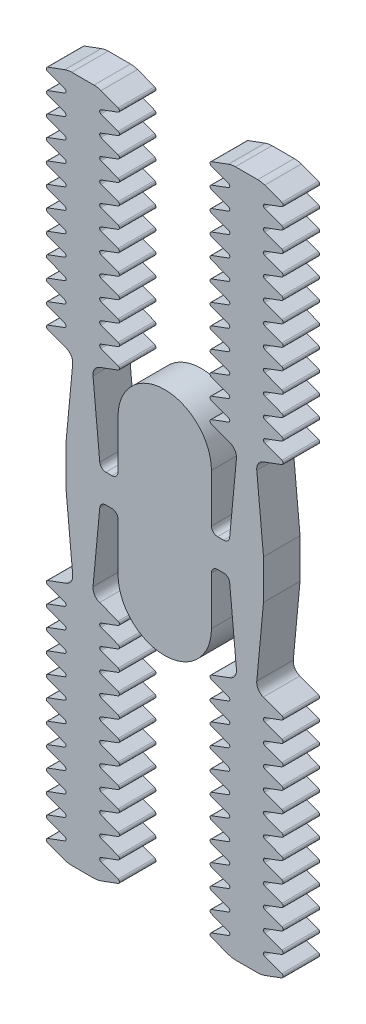
from build123d import *

# Parameters (mm, degrees)
BOSS_EXTRUDE1_DEPTH = 18


with BuildPart() as part:
    # Sketch1 → Boss-Extrude1 (new body)
    with BuildSketch(Plane.XY):
        with BuildLine():
            Line((23, 33.741347448), (23, 10))
            ThreePointArc((23, 10), (23.878679656, 7.878679656), (26, 7))
            Line((26, 7), (29.013205013, 7))
            ThreePointArc((29.013205013, 7), (31.032672098, 7.781497646), (32, 9.718831538))
            Line((32, 9.718831538), (35.321269761, 45))
            ThreePointArc((35.321269761, 45), (34.577858607, 48.127246847), (32.084323625, 50.155698542))
            Line((32.084323625, 50.155698542), (22.973060659, 53.540131589))
            ThreePointArc((22.973060659, 53.540131589), (22.321269761, 54.477548477), (22.973060659, 55.414965365))
            Line((22.973060659, 55.414965365), (31.386349055, 58.540131589))
            ThreePointArc((31.386349055, 58.540131589), (32.038139954, 59.477548477), (31.386349055, 60.414965365))
            Line((31.386349055, 60.414965365), (22.973060659, 63.540131589))
            ThreePointArc((22.973060659, 63.540131589), (22.321269761, 64.477548477), (22.973060659, 65.414965365))
            Line((22.973060659, 65.414965365), (31.386349055, 68.540131589))
            ThreePointArc((31.386349055, 68.540131589), (32.038140307, 69.47754842), (31.386349409, 70.414965496))
            Line((31.386349409, 70.414965496), (22.973061013, 73.540131721))
            ThreePointArc((22.973061013, 73.540131721), (22.321270115, 74.477548608), (22.973061013, 75.414965496))
            Line((22.973061013, 75.414965496), (31.386349763, 78.540131852))
            ThreePointArc((31.386349763, 78.540131852), (32.038140661, 79.47754874), (31.386349763, 80.414965627))
            Line((31.386349763, 80.414965627), (22.973061367, 83.540131852))
            ThreePointArc((22.973061367, 83.540131852), (22.321270469, 84.47754874), (22.973061367, 85.414965627))
            Line((22.973061367, 85.414965627), (31.386350116, 88.540131983))
            ThreePointArc((31.386350116, 88.540131983), (32.038141014, 89.477548871), (31.386350116, 90.414965759))
            Line((31.386350116, 90.414965759), (22.97306172, 93.540131983))
            ThreePointArc((22.97306172, 93.540131983), (22.321270822, 94.477548871), (22.97306172, 95.414965759))
            Line((22.97306172, 95.414965759), (31.38635047, 98.540132115))
            ThreePointArc((31.38635047, 98.540132115), (32.038141368, 99.477549002), (31.38635047, 100.41496589))
            Line((31.38635047, 100.41496589), (22.973062074, 103.540132115))
            ThreePointArc((22.973062074, 103.540132115), (22.321271176, 104.477549002), (22.973062074, 105.41496589))
            Line((22.973062074, 105.41496589), (31.386350823, 108.540132246))
            ThreePointArc((31.386350823, 108.540132246), (32.038141722, 109.477549134), (31.386350823, 110.414966021))
            Line((31.386350823, 110.414966021), (22.973062428, 113.540132246))
            ThreePointArc((22.973062428, 113.540132246), (22.321271529, 114.477549134), (22.973062428, 115.414966021))
            Line((22.973062428, 115.414966021), (31.386351177, 118.540132377))
            ThreePointArc((31.386351177, 118.540132377), (32.038142075, 119.477549265), (31.386351177, 120.414966153))
            Line((31.386351177, 120.414966153), (22.973062781, 123.540132377))
            ThreePointArc((22.973062781, 123.540132377), (22.321271883, 124.477549265), (22.973062781, 125.414966153))
            Line((22.973062781, 125.414966153), (31.386351531, 128.540132509))
            ThreePointArc((31.386351531, 128.540132509), (32.038142429, 129.477549396), (31.386351531, 130.414966284))
            Line((31.386351531, 130.414966284), (22.973063135, 133.540132509))
            ThreePointArc((22.973063135, 133.540132509), (22.321272237, 134.477549396), (22.973063135, 135.414966284))
            Line((22.973063135, 135.414966284), (31.386351884, 138.54013264))
            ThreePointArc((31.386351884, 138.54013264), (32.038142782, 139.477549528), (31.386351884, 140.414966415))
            Line((31.386351884, 140.414966415), (22.973063488, 143.54013264))
            ThreePointArc((22.973063488, 143.54013264), (22.32127259, 144.477549528), (22.973063488, 145.414966415))
            Line((22.973063488, 145.414966415), (31.386352238, 148.540132771))
            ThreePointArc((31.386352238, 148.540132771), (32.038143136, 149.477549659), (31.386352238, 150.414966547))
            Line((31.386352238, 150.414966547), (22.973063842, 153.540132771))
            ThreePointArc((22.973063842, 153.540132771), (22.321272944, 154.477549659), (22.973063842, 155.414966547))
            Line((22.973063842, 155.414966547), (31.386352591, 158.540132903))
            ThreePointArc((31.386352591, 158.540132903), (32.03814349, 159.47754979), (31.386352591, 160.414966678))
            Line((31.386352591, 160.414966678), (22.973064196, 163.540132903))
            ThreePointArc((22.973064196, 163.540132903), (22.321273297, 164.47754979), (22.973064196, 165.414966678))
            Line((22.973064196, 165.414966678), (31.386352591, 168.540132903))
            ThreePointArc((31.386352591, 168.540132903), (33.082959494, 169.005275306), (34.834824138, 169.165907512))
            Line((34.834824138, 169.165907512), (45.807715385, 169.165907512))
            ThreePointArc((45.807715385, 169.165907512), (47.559580029, 169.005275306), (49.256186931, 168.540132903))
            Line((49.256186931, 168.540132903), (57.669475327, 165.414966678))
            ThreePointArc((57.669475327, 165.414966678), (58.321266225, 164.47754979), (57.669475327, 163.540132903))
            Line((57.669475327, 163.540132903), (49.256186931, 160.414966678))
            ThreePointArc((49.256186931, 160.414966678), (48.604396033, 159.47754979), (49.256186931, 158.540132903))
            Line((49.256186931, 158.540132903), (57.669475681, 155.414966547))
            ThreePointArc((57.669475681, 155.414966547), (58.321266579, 154.477549659), (57.669475681, 153.540132771))
            Line((57.669475681, 153.540132771), (49.256187285, 150.414966547))
            ThreePointArc((49.256187285, 150.414966547), (48.604396387, 149.477549659), (49.256187285, 148.540132771))
            Line((49.256187285, 148.540132771), (57.669476034, 145.414966415))
            ThreePointArc((57.669476034, 145.414966415), (58.321266932, 144.477549528), (57.669476034, 143.54013264))
            Line((57.669476034, 143.54013264), (49.256187638, 140.414966415))
            ThreePointArc((49.256187638, 140.414966415), (48.60439674, 139.477549528), (49.256187638, 138.54013264))
            Line((49.256187638, 138.54013264), (57.669476388, 135.414966284))
            ThreePointArc((57.669476388, 135.414966284), (58.321267286, 134.477549396), (57.669476388, 133.540132509))
            Line((57.669476388, 133.540132509), (49.256187992, 130.414966284))
            ThreePointArc((49.256187992, 130.414966284), (48.604397094, 129.477549396), (49.256187992, 128.540132509))
            Line((49.256187992, 128.540132509), (57.669476742, 125.414966153))
            ThreePointArc((57.669476742, 125.414966153), (58.32126764, 124.477549265), (57.669476742, 123.540132377))
            Line((57.669476742, 123.540132377), (49.256188346, 120.414966153))
            ThreePointArc((49.256188346, 120.414966153), (48.604397448, 119.477549265), (49.256188346, 118.540132377))
            Line((49.256188346, 118.540132377), (57.669477095, 115.414966021))
            ThreePointArc((57.669477095, 115.414966021), (58.321267993, 114.477549134), (57.669477095, 113.540132246))
            Line((57.669477095, 113.540132246), (49.256188699, 110.414966021))
            ThreePointArc((49.256188699, 110.414966021), (48.604397801, 109.477549134), (49.256188699, 108.540132246))
            Line((49.256188699, 108.540132246), (57.669477449, 105.41496589))
            ThreePointArc((57.669477449, 105.41496589), (58.321268347, 104.477549002), (57.669477449, 103.540132115))
            Line((57.669477449, 103.540132115), (49.256189053, 100.41496589))
            ThreePointArc((49.256189053, 100.41496589), (48.604398155, 99.477549002), (49.256189053, 98.540132115))
            Line((49.256189053, 98.540132115), (57.669477802, 95.414965759))
            ThreePointArc((57.669477802, 95.414965759), (58.321268701, 94.477548871), (57.669477802, 93.540131983))
            Line((57.669477802, 93.540131983), (49.256189406, 90.414965759))
            ThreePointArc((49.256189406, 90.414965759), (48.604398508, 89.477548871), (49.256189406, 88.540131983))
            Line((49.256189406, 88.540131983), (57.669478156, 85.414965627))
            ThreePointArc((57.669478156, 85.414965627), (58.321269054, 84.47754874), (57.669478156, 83.540131852))
            Line((57.669478156, 83.540131852), (49.25618976, 80.414965627))
            ThreePointArc((49.25618976, 80.414965627), (48.604398862, 79.47754874), (49.25618976, 78.540131852))
            Line((49.25618976, 78.540131852), (57.66947851, 75.414965496))
            ThreePointArc((57.66947851, 75.414965496), (58.321269408, 74.477548608), (57.66947851, 73.540131721))
            Line((57.66947851, 73.540131721), (49.256190114, 70.414965496))
            ThreePointArc((49.256190114, 70.414965496), (48.604399216, 69.47754842), (49.256190467, 68.540131589))
            Line((49.256190467, 68.540131589), (57.669478863, 65.414965365))
            ThreePointArc((57.669478863, 65.414965365), (58.321269761, 64.477548477), (57.669478863, 63.540131589))
            Line((57.669478863, 63.540131589), (49.256190467, 60.414965365))
            ThreePointArc((49.256190467, 60.414965365), (48.604399569, 59.477548477), (49.256190467, 58.540131589))
            Line((49.256190467, 58.540131589), (57.669478863, 55.414965365))
            ThreePointArc((57.669478863, 55.414965365), (58.321269761, 54.477548477), (57.669478863, 53.540131589))
            Line((57.669478863, 53.540131589), (48.558215898, 50.155698542))
            ThreePointArc((48.558215898, 50.155698542), (46.064680916, 48.127246847), (45.321269761, 45))
            Line((45.321269761, 45), (48.642539523, 9.718831538))
            Line((48.642539523, 9.718831538), (48.642539523, -9.718831538))
            Line((48.642539523, -9.718831538), (45.321269761, -45))
            ThreePointArc((45.321269761, -45), (46.064680916, -48.127246847), (48.558215898, -50.155698542))
            Line((48.558215898, -50.155698542), (57.669478863, -53.540131589))
            ThreePointArc((57.669478863, -53.540131589), (58.321269761, -54.477548477), (57.669478863, -55.414965365))
            Line((57.669478863, -55.414965365), (49.256190467, -58.540131589))
            ThreePointArc((49.256190467, -58.540131589), (48.604399569, -59.477548477), (49.256190467, -60.414965365))
            Line((49.256190467, -60.414965365), (57.669478863, -63.540131589))
            ThreePointArc((57.669478863, -63.540131589), (58.321269761, -64.477548477), (57.669478863, -65.414965365))
            Line((57.669478863, -65.414965365), (49.256190467, -68.540131589))
            ThreePointArc((49.256190467, -68.540131589), (48.604399216, -69.47754842), (49.256190114, -70.414965496))
            Line((49.256190114, -70.414965496), (57.66947851, -73.540131721))
            ThreePointArc((57.66947851, -73.540131721), (58.321269408, -74.477548608), (57.66947851, -75.414965496))
            Line((57.66947851, -75.414965496), (49.25618976, -78.540131852))
            ThreePointArc((49.25618976, -78.540131852), (48.604398862, -79.47754874), (49.25618976, -80.414965627))
            Line((49.25618976, -80.414965627), (57.669478156, -83.540131852))
            ThreePointArc((57.669478156, -83.540131852), (58.321269054, -84.47754874), (57.669478156, -85.414965627))
            Line((57.669478156, -85.414965627), (49.256189406, -88.540131983))
            ThreePointArc((49.256189406, -88.540131983), (48.604398508, -89.477548871), (49.256189406, -90.414965759))
            Line((49.256189406, -90.414965759), (57.669477802, -93.540131983))
            ThreePointArc((57.669477802, -93.540131983), (58.321268701, -94.477548871), (57.669477802, -95.414965759))
            Line((57.669477802, -95.414965759), (49.256189053, -98.540132115))
            ThreePointArc((49.256189053, -98.540132115), (48.604398155, -99.477549002), (49.256189053, -100.41496589))
            Line((49.256189053, -100.41496589), (57.669477449, -103.540132115))
            ThreePointArc((57.669477449, -103.540132115), (58.321268347, -104.477549002), (57.669477449, -105.41496589))
            Line((57.669477449, -105.41496589), (49.256188699, -108.540132246))
            ThreePointArc((49.256188699, -108.540132246), (48.604397801, -109.477549134), (49.256188699, -110.414966021))
            Line((49.256188699, -110.414966021), (57.669477095, -113.540132246))
            ThreePointArc((57.669477095, -113.540132246), (58.321267993, -114.477549134), (57.669477095, -115.414966021))
            Line((57.669477095, -115.414966021), (49.256188346, -118.540132377))
            ThreePointArc((49.256188346, -118.540132377), (48.604397448, -119.477549265), (49.256188346, -120.414966153))
            Line((49.256188346, -120.414966153), (57.669476742, -123.540132377))
            ThreePointArc((57.669476742, -123.540132377), (58.32126764, -124.477549265), (57.669476742, -125.414966153))
            Line((57.669476742, -125.414966153), (49.256187992, -128.540132509))
            ThreePointArc((49.256187992, -128.540132509), (48.604397094, -129.477549396), (49.256187992, -130.414966284))
            Line((49.256187992, -130.414966284), (57.669476388, -133.540132509))
            ThreePointArc((57.669476388, -133.540132509), (58.321267286, -134.477549396), (57.669476388, -135.414966284))
            Line((57.669476388, -135.414966284), (49.256187638, -138.54013264))
            ThreePointArc((49.256187638, -138.54013264), (48.60439674, -139.477549528), (49.256187638, -140.414966415))
            Line((49.256187638, -140.414966415), (57.669476034, -143.54013264))
            ThreePointArc((57.669476034, -143.54013264), (58.321266932, -144.477549528), (57.669476034, -145.414966415))
            Line((57.669476034, -145.414966415), (49.256187285, -148.540132771))
            ThreePointArc((49.256187285, -148.540132771), (48.604396387, -149.477549659), (49.256187285, -150.414966547))
            Line((49.256187285, -150.414966547), (57.669475681, -153.540132771))
            ThreePointArc((57.669475681, -153.540132771), (58.321266579, -154.477549659), (57.669475681, -155.414966547))
            Line((57.669475681, -155.414966547), (49.256186931, -158.540132903))
            ThreePointArc((49.256186931, -158.540132903), (48.604396033, -159.47754979), (49.256186931, -160.414966678))
            Line((49.256186931, -160.414966678), (57.669475327, -163.540132903))
            ThreePointArc((57.669475327, -163.540132903), (58.321266225, -164.47754979), (57.669475327, -165.414966678))
            Line((57.669475327, -165.414966678), (49.256186931, -168.540132903))
            ThreePointArc((49.256186931, -168.540132903), (47.559580029, -169.005275306), (45.807715385, -169.165907512))
            Line((45.807715385, -169.165907512), (34.834824138, -169.165907512))
            ThreePointArc((34.834824138, -169.165907512), (33.082959494, -169.005275306), (31.386352591, -168.540132903))
            Line((31.386352591, -168.540132903), (22.973064196, -165.414966678))
            ThreePointArc((22.973064196, -165.414966678), (22.321273297, -164.47754979), (22.973064196, -163.540132903))
            Line((22.973064196, -163.540132903), (31.386352591, -160.414966678))
            ThreePointArc((31.386352591, -160.414966678), (32.03814349, -159.47754979), (31.386352591, -158.540132903))
            Line((31.386352591, -158.540132903), (22.973063842, -155.414966547))
            ThreePointArc((22.973063842, -155.414966547), (22.321272944, -154.477549659), (22.973063842, -153.540132771))
            Line((22.973063842, -153.540132771), (31.386352238, -150.414966547))
            ThreePointArc((31.386352238, -150.414966547), (32.038143136, -149.477549659), (31.386352238, -148.540132771))
            Line((31.386352238, -148.540132771), (22.973063488, -145.414966415))
            ThreePointArc((22.973063488, -145.414966415), (22.32127259, -144.477549528), (22.973063488, -143.54013264))
            Line((22.973063488, -143.54013264), (31.386351884, -140.414966415))
            ThreePointArc((31.386351884, -140.414966415), (32.038142782, -139.477549528), (31.386351884, -138.54013264))
            Line((31.386351884, -138.54013264), (22.973063135, -135.414966284))
            ThreePointArc((22.973063135, -135.414966284), (22.321272237, -134.477549396), (22.973063135, -133.540132509))
            Line((22.973063135, -133.540132509), (31.386351531, -130.414966284))
            ThreePointArc((31.386351531, -130.414966284), (32.038142429, -129.477549396), (31.386351531, -128.540132509))
            Line((31.386351531, -128.540132509), (22.973062781, -125.414966153))
            ThreePointArc((22.973062781, -125.414966153), (22.321271883, -124.477549265), (22.973062781, -123.540132377))
            Line((22.973062781, -123.540132377), (31.386351177, -120.414966153))
            ThreePointArc((31.386351177, -120.414966153), (32.038142075, -119.477549265), (31.386351177, -118.540132377))
            Line((31.386351177, -118.540132377), (22.973062428, -115.414966021))
            ThreePointArc((22.973062428, -115.414966021), (22.321271529, -114.477549134), (22.973062428, -113.540132246))
            Line((22.973062428, -113.540132246), (31.386350823, -110.414966021))
            ThreePointArc((31.386350823, -110.414966021), (32.038141722, -109.477549134), (31.386350823, -108.540132246))
            Line((31.386350823, -108.540132246), (22.973062074, -105.41496589))
            ThreePointArc((22.973062074, -105.41496589), (22.321271176, -104.477549002), (22.973062074, -103.540132115))
            Line((22.973062074, -103.540132115), (31.38635047, -100.41496589))
            ThreePointArc((31.38635047, -100.41496589), (32.038141368, -99.477549002), (31.38635047, -98.540132115))
            Line((31.38635047, -98.540132115), (22.97306172, -95.414965759))
            ThreePointArc((22.97306172, -95.414965759), (22.321270822, -94.477548871), (22.97306172, -93.540131983))
            Line((22.97306172, -93.540131983), (31.386350116, -90.414965759))
            ThreePointArc((31.386350116, -90.414965759), (32.038141014, -89.477548871), (31.386350116, -88.540131983))
            Line((31.386350116, -88.540131983), (22.973061367, -85.414965627))
            ThreePointArc((22.973061367, -85.414965627), (22.321270469, -84.47754874), (22.973061367, -83.540131852))
            Line((22.973061367, -83.540131852), (31.386349763, -80.414965627))
            ThreePointArc((31.386349763, -80.414965627), (32.038140661, -79.47754874), (31.386349763, -78.540131852))
            Line((31.386349763, -78.540131852), (22.973061013, -75.414965496))
            ThreePointArc((22.973061013, -75.414965496), (22.321270115, -74.477548608), (22.973061013, -73.540131721))
            Line((22.973061013, -73.540131721), (31.386349409, -70.414965496))
            ThreePointArc((31.386349409, -70.414965496), (32.038140307, -69.47754842), (31.386349055, -68.540131589))
            Line((31.386349055, -68.540131589), (22.973060659, -65.414965365))
            ThreePointArc((22.973060659, -65.414965365), (22.321269761, -64.477548477), (22.973060659, -63.540131589))
            Line((22.973060659, -63.540131589), (31.386349055, -60.414965365))
            ThreePointArc((31.386349055, -60.414965365), (32.038139954, -59.477548477), (31.386349055, -58.540131589))
            Line((31.386349055, -58.540131589), (22.973060659, -55.414965365))
            ThreePointArc((22.973060659, -55.414965365), (22.321269761, -54.477548477), (22.973060659, -53.540131589))
            Line((22.973060659, -53.540131589), (32.084323625, -50.155698542))
            ThreePointArc((32.084323625, -50.155698542), (34.577858607, -48.127246847), (35.321269761, -45))
            Line((35.321269761, -45), (32, -9.718831538))
            ThreePointArc((32, -9.718831538), (31.032672098, -7.781497646), (29.013205013, -7))
            Line((29.013205013, -7), (26, -7))
            ThreePointArc((26, -7), (23.878679656, -7.878679656), (23, -10))
            Line((23, -10), (23, -33.741347448))
            ThreePointArc((23, -33.741347448), (0, -56.741347448), (-23, -33.741347448))
            Line((-23, -33.741347448), (-23, -10))
            ThreePointArc((-23, -10), (-23.878679656, -7.878679656), (-26, -7))
            Line((-26, -7), (-29.013205013, -7))
            ThreePointArc((-29.013205013, -7), (-31.032672098, -7.781497646), (-32, -9.718831538))
            Line((-32, -9.718831538), (-35.321269761, -45))
            ThreePointArc((-35.321269761, -45), (-34.577858607, -48.127246847), (-32.084323625, -50.155698542))
            Line((-32.084323625, -50.155698542), (-22.973060659, -53.540131589))
            ThreePointArc((-22.973060659, -53.540131589), (-22.321269761, -54.477548477), (-22.973060659, -55.414965365))
            Line((-22.973060659, -55.414965365), (-31.386349055, -58.540131589))
            ThreePointArc((-31.386349055, -58.540131589), (-32.038139954, -59.477548477), (-31.386349055, -60.414965365))
            Line((-31.386349055, -60.414965365), (-22.973060659, -63.540131589))
            ThreePointArc((-22.973060659, -63.540131589), (-22.321269761, -64.477548477), (-22.973060659, -65.414965365))
            Line((-22.973060659, -65.414965365), (-31.386349055, -68.540131589))
            ThreePointArc((-31.386349055, -68.540131589), (-32.038140307, -69.47754842), (-31.386349409, -70.414965496))
            Line((-31.386349409, -70.414965496), (-22.973061013, -73.540131721))
            ThreePointArc((-22.973061013, -73.540131721), (-22.321270115, -74.477548608), (-22.973061013, -75.414965496))
            Line((-22.973061013, -75.414965496), (-31.386349763, -78.540131852))
            ThreePointArc((-31.386349763, -78.540131852), (-32.038140661, -79.47754874), (-31.386349763, -80.414965627))
            Line((-31.386349763, -80.414965627), (-22.973061367, -83.540131852))
            ThreePointArc((-22.973061367, -83.540131852), (-22.321270469, -84.47754874), (-22.973061367, -85.414965627))
            Line((-22.973061367, -85.414965627), (-31.386350116, -88.540131983))
            ThreePointArc((-31.386350116, -88.540131983), (-32.038141014, -89.477548871), (-31.386350116, -90.414965759))
            Line((-31.386350116, -90.414965759), (-22.97306172, -93.540131983))
            ThreePointArc((-22.97306172, -93.540131983), (-22.321270822, -94.477548871), (-22.97306172, -95.414965759))
            Line((-22.97306172, -95.414965759), (-31.38635047, -98.540132115))
            ThreePointArc((-31.38635047, -98.540132115), (-32.038141368, -99.477549002), (-31.38635047, -100.41496589))
            Line((-31.38635047, -100.41496589), (-22.973062074, -103.540132115))
            ThreePointArc((-22.973062074, -103.540132115), (-22.321271176, -104.477549002), (-22.973062074, -105.41496589))
            Line((-22.973062074, -105.41496589), (-31.386350823, -108.540132246))
            ThreePointArc((-31.386350823, -108.540132246), (-32.038141722, -109.477549134), (-31.386350823, -110.414966021))
            Line((-31.386350823, -110.414966021), (-22.973062428, -113.540132246))
            ThreePointArc((-22.973062428, -113.540132246), (-22.321271529, -114.477549134), (-22.973062428, -115.414966021))
            Line((-22.973062428, -115.414966021), (-31.386351177, -118.540132377))
            ThreePointArc((-31.386351177, -118.540132377), (-32.038142075, -119.477549265), (-31.386351177, -120.414966153))
            Line((-31.386351177, -120.414966153), (-22.973062781, -123.540132377))
            ThreePointArc((-22.973062781, -123.540132377), (-22.321271883, -124.477549265), (-22.973062781, -125.414966153))
            Line((-22.973062781, -125.414966153), (-31.386351531, -128.540132509))
            ThreePointArc((-31.386351531, -128.540132509), (-32.038142429, -129.477549396), (-31.386351531, -130.414966284))
            Line((-31.386351531, -130.414966284), (-22.973063135, -133.540132509))
            ThreePointArc((-22.973063135, -133.540132509), (-22.321272237, -134.477549396), (-22.973063135, -135.414966284))
            Line((-22.973063135, -135.414966284), (-31.386351884, -138.54013264))
            ThreePointArc((-31.386351884, -138.54013264), (-32.038142782, -139.477549528), (-31.386351884, -140.414966415))
            Line((-31.386351884, -140.414966415), (-22.973063488, -143.54013264))
            ThreePointArc((-22.973063488, -143.54013264), (-22.32127259, -144.477549528), (-22.973063488, -145.414966415))
            Line((-22.973063488, -145.414966415), (-31.386352238, -148.540132771))
            ThreePointArc((-31.386352238, -148.540132771), (-32.038143136, -149.477549659), (-31.386352238, -150.414966547))
            Line((-31.386352238, -150.414966547), (-22.973063842, -153.540132771))
            ThreePointArc((-22.973063842, -153.540132771), (-22.321272944, -154.477549659), (-22.973063842, -155.414966547))
            Line((-22.973063842, -155.414966547), (-31.386352591, -158.540132903))
            ThreePointArc((-31.386352591, -158.540132903), (-32.03814349, -159.47754979), (-31.386352591, -160.414966678))
            Line((-31.386352591, -160.414966678), (-22.973064196, -163.540132903))
            ThreePointArc((-22.973064196, -163.540132903), (-22.321273297, -164.47754979), (-22.973064196, -165.414966678))
            Line((-22.973064196, -165.414966678), (-31.386352591, -168.540132903))
            ThreePointArc((-31.386352591, -168.540132903), (-33.082959494, -169.005275306), (-34.834824138, -169.165907512))
            Line((-34.834824138, -169.165907512), (-45.807715385, -169.165907512))
            ThreePointArc((-45.807715385, -169.165907512), (-47.559580029, -169.005275306), (-49.256186931, -168.540132903))
            Line((-49.256186931, -168.540132903), (-57.669475327, -165.414966678))
            ThreePointArc((-57.669475327, -165.414966678), (-58.321266225, -164.47754979), (-57.669475327, -163.540132903))
            Line((-57.669475327, -163.540132903), (-49.256186931, -160.414966678))
            ThreePointArc((-49.256186931, -160.414966678), (-48.604396033, -159.47754979), (-49.256186931, -158.540132903))
            Line((-49.256186931, -158.540132903), (-57.669475681, -155.414966547))
            ThreePointArc((-57.669475681, -155.414966547), (-58.321266579, -154.477549659), (-57.669475681, -153.540132771))
            Line((-57.669475681, -153.540132771), (-49.256187285, -150.414966547))
            ThreePointArc((-49.256187285, -150.414966547), (-48.604396387, -149.477549659), (-49.256187285, -148.540132771))
            Line((-49.256187285, -148.540132771), (-57.669476034, -145.414966415))
            ThreePointArc((-57.669476034, -145.414966415), (-58.321266932, -144.477549528), (-57.669476034, -143.54013264))
            Line((-57.669476034, -143.54013264), (-49.256187638, -140.414966415))
            ThreePointArc((-49.256187638, -140.414966415), (-48.60439674, -139.477549528), (-49.256187638, -138.54013264))
            Line((-49.256187638, -138.54013264), (-57.669476388, -135.414966284))
            ThreePointArc((-57.669476388, -135.414966284), (-58.321267286, -134.477549396), (-57.669476388, -133.540132509))
            Line((-57.669476388, -133.540132509), (-49.256187992, -130.414966284))
            ThreePointArc((-49.256187992, -130.414966284), (-48.604397094, -129.477549396), (-49.256187992, -128.540132509))
            Line((-49.256187992, -128.540132509), (-57.669476742, -125.414966153))
            ThreePointArc((-57.669476742, -125.414966153), (-58.32126764, -124.477549265), (-57.669476742, -123.540132377))
            Line((-57.669476742, -123.540132377), (-49.256188346, -120.414966153))
            ThreePointArc((-49.256188346, -120.414966153), (-48.604397448, -119.477549265), (-49.256188346, -118.540132377))
            Line((-49.256188346, -118.540132377), (-57.669477095, -115.414966021))
            ThreePointArc((-57.669477095, -115.414966021), (-58.321267993, -114.477549134), (-57.669477095, -113.540132246))
            Line((-57.669477095, -113.540132246), (-49.256188699, -110.414966021))
            ThreePointArc((-49.256188699, -110.414966021), (-48.604397801, -109.477549134), (-49.256188699, -108.540132246))
            Line((-49.256188699, -108.540132246), (-57.669477449, -105.41496589))
            ThreePointArc((-57.669477449, -105.41496589), (-58.321268347, -104.477549002), (-57.669477449, -103.540132115))
            Line((-57.669477449, -103.540132115), (-49.256189053, -100.41496589))
            ThreePointArc((-49.256189053, -100.41496589), (-48.604398155, -99.477549002), (-49.256189053, -98.540132115))
            Line((-49.256189053, -98.540132115), (-57.669477802, -95.414965759))
            ThreePointArc((-57.669477802, -95.414965759), (-58.321268701, -94.477548871), (-57.669477802, -93.540131983))
            Line((-57.669477802, -93.540131983), (-49.256189406, -90.414965759))
            ThreePointArc((-49.256189406, -90.414965759), (-48.604398508, -89.477548871), (-49.256189406, -88.540131983))
            Line((-49.256189406, -88.540131983), (-57.669478156, -85.414965627))
            ThreePointArc((-57.669478156, -85.414965627), (-58.321269054, -84.47754874), (-57.669478156, -83.540131852))
            Line((-57.669478156, -83.540131852), (-49.25618976, -80.414965627))
            ThreePointArc((-49.25618976, -80.414965627), (-48.604398862, -79.47754874), (-49.25618976, -78.540131852))
            Line((-49.25618976, -78.540131852), (-57.66947851, -75.414965496))
            ThreePointArc((-57.66947851, -75.414965496), (-58.321269408, -74.477548608), (-57.66947851, -73.540131721))
            Line((-57.66947851, -73.540131721), (-49.256190114, -70.414965496))
            ThreePointArc((-49.256190114, -70.414965496), (-48.604399216, -69.47754842), (-49.256190467, -68.540131589))
            Line((-49.256190467, -68.540131589), (-57.669478863, -65.414965365))
            ThreePointArc((-57.669478863, -65.414965365), (-58.321269761, -64.477548477), (-57.669478863, -63.540131589))
            Line((-57.669478863, -63.540131589), (-49.256190467, -60.414965365))
            ThreePointArc((-49.256190467, -60.414965365), (-48.604399569, -59.477548477), (-49.256190467, -58.540131589))
            Line((-49.256190467, -58.540131589), (-57.669478863, -55.414965365))
            ThreePointArc((-57.669478863, -55.414965365), (-58.321269761, -54.477548477), (-57.669478863, -53.540131589))
            Line((-57.669478863, -53.540131589), (-48.558215898, -50.155698542))
            ThreePointArc((-48.558215898, -50.155698542), (-46.064680916, -48.127246847), (-45.321269761, -45))
            Line((-45.321269761, -45), (-48.642539523, -9.718831538))
            Line((-48.642539523, -9.718831538), (-48.642539523, 9.718831538))
            Line((-48.642539523, 9.718831538), (-45.321269761, 45))
            ThreePointArc((-45.321269761, 45), (-46.064680916, 48.127246847), (-48.558215898, 50.155698542))
            Line((-48.558215898, 50.155698542), (-57.669478863, 53.540131589))
            ThreePointArc((-57.669478863, 53.540131589), (-58.321269761, 54.477548477), (-57.669478863, 55.414965365))
            Line((-57.669478863, 55.414965365), (-49.256190467, 58.540131589))
            ThreePointArc((-49.256190467, 58.540131589), (-48.604399569, 59.477548477), (-49.256190467, 60.414965365))
            Line((-49.256190467, 60.414965365), (-57.669478863, 63.540131589))
            ThreePointArc((-57.669478863, 63.540131589), (-58.321269761, 64.477548477), (-57.669478863, 65.414965365))
            Line((-57.669478863, 65.414965365), (-49.256190467, 68.540131589))
            ThreePointArc((-49.256190467, 68.540131589), (-48.604399216, 69.47754842), (-49.256190114, 70.414965496))
            Line((-49.256190114, 70.414965496), (-57.66947851, 73.540131721))
            ThreePointArc((-57.66947851, 73.540131721), (-58.321269408, 74.477548608), (-57.66947851, 75.414965496))
            Line((-57.66947851, 75.414965496), (-49.25618976, 78.540131852))
            ThreePointArc((-49.25618976, 78.540131852), (-48.604398862, 79.47754874), (-49.25618976, 80.414965627))
            Line((-49.25618976, 80.414965627), (-57.669478156, 83.540131852))
            ThreePointArc((-57.669478156, 83.540131852), (-58.321269054, 84.47754874), (-57.669478156, 85.414965627))
            Line((-57.669478156, 85.414965627), (-49.256189406, 88.540131983))
            ThreePointArc((-49.256189406, 88.540131983), (-48.604398508, 89.477548871), (-49.256189406, 90.414965759))
            Line((-49.256189406, 90.414965759), (-57.669477802, 93.540131983))
            ThreePointArc((-57.669477802, 93.540131983), (-58.321268701, 94.477548871), (-57.669477802, 95.414965759))
            Line((-57.669477802, 95.414965759), (-49.256189053, 98.540132115))
            ThreePointArc((-49.256189053, 98.540132115), (-48.604398155, 99.477549002), (-49.256189053, 100.41496589))
            Line((-49.256189053, 100.41496589), (-57.669477449, 103.540132115))
            ThreePointArc((-57.669477449, 103.540132115), (-58.321268347, 104.477549002), (-57.669477449, 105.41496589))
            Line((-57.669477449, 105.41496589), (-49.256188699, 108.540132246))
            ThreePointArc((-49.256188699, 108.540132246), (-48.604397801, 109.477549134), (-49.256188699, 110.414966021))
            Line((-49.256188699, 110.414966021), (-57.669477095, 113.540132246))
            ThreePointArc((-57.669477095, 113.540132246), (-58.321267993, 114.477549134), (-57.669477095, 115.414966021))
            Line((-57.669477095, 115.414966021), (-49.256188346, 118.540132377))
            ThreePointArc((-49.256188346, 118.540132377), (-48.604397448, 119.477549265), (-49.256188346, 120.414966153))
            Line((-49.256188346, 120.414966153), (-57.669476742, 123.540132377))
            ThreePointArc((-57.669476742, 123.540132377), (-58.32126764, 124.477549265), (-57.669476742, 125.414966153))
            Line((-57.669476742, 125.414966153), (-49.256187992, 128.540132509))
            ThreePointArc((-49.256187992, 128.540132509), (-48.604397094, 129.477549396), (-49.256187992, 130.414966284))
            Line((-49.256187992, 130.414966284), (-57.669476388, 133.540132509))
            ThreePointArc((-57.669476388, 133.540132509), (-58.321267286, 134.477549396), (-57.669476388, 135.414966284))
            Line((-57.669476388, 135.414966284), (-49.256187638, 138.54013264))
            ThreePointArc((-49.256187638, 138.54013264), (-48.60439674, 139.477549528), (-49.256187638, 140.414966415))
            Line((-49.256187638, 140.414966415), (-57.669476034, 143.54013264))
            ThreePointArc((-57.669476034, 143.54013264), (-58.321266932, 144.477549528), (-57.669476034, 145.414966415))
            Line((-57.669476034, 145.414966415), (-49.256187285, 148.540132771))
            ThreePointArc((-49.256187285, 148.540132771), (-48.604396387, 149.477549659), (-49.256187285, 150.414966547))
            Line((-49.256187285, 150.414966547), (-57.669475681, 153.540132771))
            ThreePointArc((-57.669475681, 153.540132771), (-58.321266579, 154.477549659), (-57.669475681, 155.414966547))
            Line((-57.669475681, 155.414966547), (-49.256186931, 158.540132903))
            ThreePointArc((-49.256186931, 158.540132903), (-48.604396033, 159.47754979), (-49.256186931, 160.414966678))
            Line((-49.256186931, 160.414966678), (-57.669475327, 163.540132903))
            ThreePointArc((-57.669475327, 163.540132903), (-58.321266225, 164.47754979), (-57.669475327, 165.414966678))
            Line((-57.669475327, 165.414966678), (-49.256186931, 168.540132903))
            ThreePointArc((-49.256186931, 168.540132903), (-47.559580029, 169.005275306), (-45.807715385, 169.165907512))
            Line((-45.807715385, 169.165907512), (-34.834824138, 169.165907512))
            ThreePointArc((-34.834824138, 169.165907512), (-33.082959494, 169.005275306), (-31.386352591, 168.540132903))
            Line((-31.386352591, 168.540132903), (-22.973064196, 165.414966678))
            ThreePointArc((-22.973064196, 165.414966678), (-22.321273297, 164.47754979), (-22.973064196, 163.540132903))
            Line((-22.973064196, 163.540132903), (-31.386352591, 160.414966678))
            ThreePointArc((-31.386352591, 160.414966678), (-32.03814349, 159.47754979), (-31.386352591, 158.540132903))
            Line((-31.386352591, 158.540132903), (-22.973063842, 155.414966547))
            ThreePointArc((-22.973063842, 155.414966547), (-22.321272944, 154.477549659), (-22.973063842, 153.540132771))
            Line((-22.973063842, 153.540132771), (-31.386352238, 150.414966547))
            ThreePointArc((-31.386352238, 150.414966547), (-32.038143136, 149.477549659), (-31.386352238, 148.540132771))
            Line((-31.386352238, 148.540132771), (-22.973063488, 145.414966415))
            ThreePointArc((-22.973063488, 145.414966415), (-22.32127259, 144.477549528), (-22.973063488, 143.54013264))
            Line((-22.973063488, 143.54013264), (-31.386351884, 140.414966415))
            ThreePointArc((-31.386351884, 140.414966415), (-32.038142782, 139.477549528), (-31.386351884, 138.54013264))
            Line((-31.386351884, 138.54013264), (-22.973063135, 135.414966284))
            ThreePointArc((-22.973063135, 135.414966284), (-22.321272237, 134.477549396), (-22.973063135, 133.540132509))
            Line((-22.973063135, 133.540132509), (-31.386351531, 130.414966284))
            ThreePointArc((-31.386351531, 130.414966284), (-32.038142429, 129.477549396), (-31.386351531, 128.540132509))
            Line((-31.386351531, 128.540132509), (-22.973062781, 125.414966153))
            ThreePointArc((-22.973062781, 125.414966153), (-22.321271883, 124.477549265), (-22.973062781, 123.540132377))
            Line((-22.973062781, 123.540132377), (-31.386351177, 120.414966153))
            ThreePointArc((-31.386351177, 120.414966153), (-32.038142075, 119.477549265), (-31.386351177, 118.540132377))
            Line((-31.386351177, 118.540132377), (-22.973062428, 115.414966021))
            ThreePointArc((-22.973062428, 115.414966021), (-22.321271529, 114.477549134), (-22.973062428, 113.540132246))
            Line((-22.973062428, 113.540132246), (-31.386350823, 110.414966021))
            ThreePointArc((-31.386350823, 110.414966021), (-32.038141722, 109.477549134), (-31.386350823, 108.540132246))
            Line((-31.386350823, 108.540132246), (-22.973062074, 105.41496589))
            ThreePointArc((-22.973062074, 105.41496589), (-22.321271176, 104.477549002), (-22.973062074, 103.540132115))
            Line((-22.973062074, 103.540132115), (-31.38635047, 100.41496589))
            ThreePointArc((-31.38635047, 100.41496589), (-32.038141368, 99.477549002), (-31.38635047, 98.540132115))
            Line((-31.38635047, 98.540132115), (-22.97306172, 95.414965759))
            ThreePointArc((-22.97306172, 95.414965759), (-22.321270822, 94.477548871), (-22.97306172, 93.540131983))
            Line((-22.97306172, 93.540131983), (-31.386350116, 90.414965759))
            ThreePointArc((-31.386350116, 90.414965759), (-32.038141014, 89.477548871), (-31.386350116, 88.540131983))
            Line((-31.386350116, 88.540131983), (-22.973061367, 85.414965627))
            ThreePointArc((-22.973061367, 85.414965627), (-22.321270469, 84.47754874), (-22.973061367, 83.540131852))
            Line((-22.973061367, 83.540131852), (-31.386349763, 80.414965627))
            ThreePointArc((-31.386349763, 80.414965627), (-32.038140661, 79.47754874), (-31.386349763, 78.540131852))
            Line((-31.386349763, 78.540131852), (-22.973061013, 75.414965496))
            ThreePointArc((-22.973061013, 75.414965496), (-22.321270115, 74.477548608), (-22.973061013, 73.540131721))
            Line((-22.973061013, 73.540131721), (-31.386349409, 70.414965496))
            ThreePointArc((-31.386349409, 70.414965496), (-32.038140307, 69.47754842), (-31.386349055, 68.540131589))
            Line((-31.386349055, 68.540131589), (-22.973060659, 65.414965365))
            ThreePointArc((-22.973060659, 65.414965365), (-22.321269761, 64.477548477), (-22.973060659, 63.540131589))
            Line((-22.973060659, 63.540131589), (-31.386349055, 60.414965365))
            ThreePointArc((-31.386349055, 60.414965365), (-32.038139954, 59.477548477), (-31.386349055, 58.540131589))
            Line((-31.386349055, 58.540131589), (-22.973060659, 55.414965365))
            ThreePointArc((-22.973060659, 55.414965365), (-22.321269761, 54.477548477), (-22.973060659, 53.540131589))
            Line((-22.973060659, 53.540131589), (-32.084323625, 50.155698542))
            ThreePointArc((-32.084323625, 50.155698542), (-34.577858607, 48.127246847), (-35.321269761, 45))
            Line((-35.321269761, 45), (-32, 9.718831538))
            ThreePointArc((-32, 9.718831538), (-31.032672098, 7.781497646), (-29.013205013, 7))
            Line((-29.013205013, 7), (-26, 7))
            ThreePointArc((-26, 7), (-23.878679656, 7.878679656), (-23, 10))
            Line((-23, 10), (-23, 33.741347448))
            ThreePointArc((-23, 33.741347448), (0, 56.741347448), (23, 33.741347448))
        make_face()
    extrude(amount=BOSS_EXTRUDE1_DEPTH)


solid = part.part
